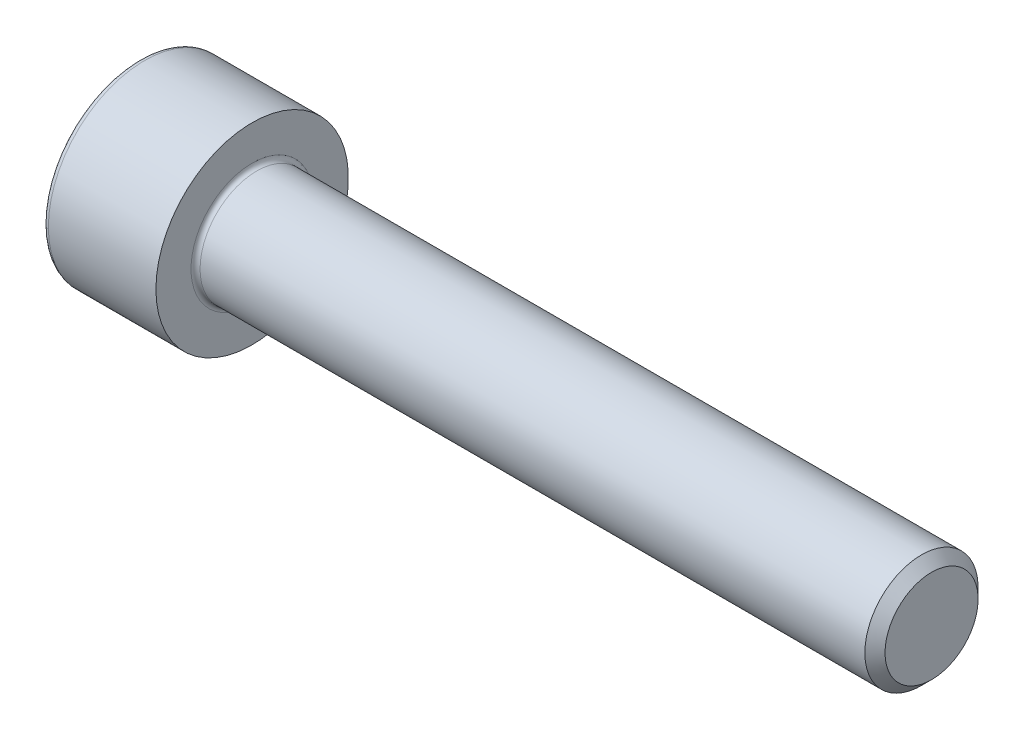
from build123d import *

# Parameters (mm, degrees)
FILLET1_R   = 0.2
FILLET2_R   = 0.25
HEX_2_DEPTH = 2.5


with BuildPart() as part:
    # BodySke → Base-Revolve (revolve)
    with BuildSketch(Plane.XY):
        Polygon((0, 0), (0, 4.25), (5, 4.25), (5, 2.5), (34.555, 2.5), (35, 2.055), (35, 0), align=None)
    revolve(axis=Axis((-31.75, 0, 0), (1, 0, 0)))

    # Fillet1
    fillet1_edges = [part.edges().sort_by_distance(p)[0] for p in [
        (5, -2.5, 0),
    ]]
    fillet(fillet1_edges, radius=FILLET1_R)

    # Fillet2
    fillet2_edges = [part.edges().sort_by_distance(p)[0] for p in [
        (0, -4.25, 0),
    ]]
    fillet(fillet2_edges, radius=FILLET2_R)

    # Sketch2 → Hex-PreBroach (revolve, cut)
    with BuildSketch(Plane.XY):
        Polygon((0, 2.042), (2.5, 2.042), (3.67894925, 0), (0, 0), align=None)
    revolve(axis=Axis((0, 0, 0), (1, 0, 0)), mode=Mode.SUBTRACT)

    # Sketch3 → Hex 2 (cut)
    with BuildSketch(Plane(origin=(0, 0, 0), x_dir=(0, 0.5, 0.866025404), z_dir=(-1, 0, 0))):
        Polygon((1.17894925, 2.042), (-1.17894925, 2.042), (-2.357898499, 0), (-1.17894925, -2.042), (1.17894925, -2.042), (2.357898499, 0), align=None)
    extrude(amount=-HEX_2_DEPTH, mode=Mode.SUBTRACT)


solid = part.part
